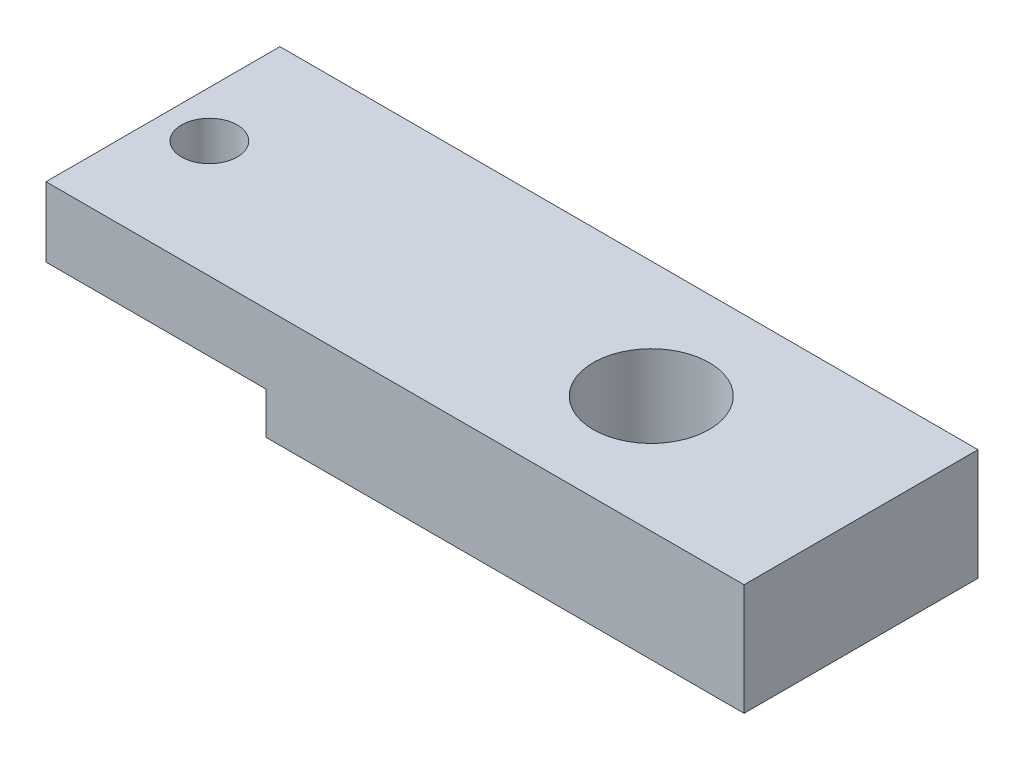
from build123d import *

# Parameters (mm, degrees)
SKETCH1_W           = 19.1008
SKETCH1_H           = 6.4008
BOSS_EXTRUDE1_DEPTH = 1.905
SKETCH2_W           = 13.081
SKETCH2_H           = 6.4008
BOSS_EXTRUDE2_DEPTH = 1.143
CUT_EXTRUDE1_REACH  = 5.048
SKETCH3_R           = 0.762
CUT_EXTRUDE2_REACH  = 5.048
SKETCH4_R           = 1.5875


with BuildPart() as part:
    # Sketch1 → Boss-Extrude1 (new body)
    with BuildSketch(Plane(origin=(0, 0, 0), x_dir=(1, 0, 0), z_dir=(0, 1, 0))):
        Rectangle(SKETCH1_W, SKETCH1_H)
    extrude(amount=BOSS_EXTRUDE1_DEPTH)

    # Sketch2 → Boss-Extrude2 (add)
    with BuildSketch(Plane(origin=(0, 0, 0), x_dir=(-1, 0, 0), z_dir=(0, -1, 0))):
        with Locations((-3.0099, 0)):
            Rectangle(SKETCH2_W, SKETCH2_H)
    extrude(amount=BOSS_EXTRUDE2_DEPTH)

    # Sketch3 → Cut-Extrude1 (cut, up to next)
    with BuildSketch(Plane(origin=(0, 1.905, 0), x_dir=(1, 0, 0), z_dir=(0, 1, 0)), mode=Mode.PRIVATE) as cut_extrude1_sk1:
        with Locations((-8.2804, 0)):
            Circle(SKETCH3_R)
    cut_extrude1_tool1 = extrude(cut_extrude1_sk1.sketch, amount=-CUT_EXTRUDE1_REACH, mode=Mode.PRIVATE) & part.part
    add(cut_extrude1_tool1.solids().sort_by_distance((-8.2804, 1.905, 0))[0], mode=Mode.SUBTRACT)

    # Sketch4 → Cut-Extrude2 (cut, up to next)
    with BuildSketch(Plane(origin=(0, 1.905, 0), x_dir=(1, 0, 0), z_dir=(0, 1, 0)), mode=Mode.PRIVATE) as cut_extrude2_sk1:
        with Locations((3.81, 0)):
            Circle(SKETCH4_R)
    cut_extrude2_tool1 = extrude(cut_extrude2_sk1.sketch, amount=-CUT_EXTRUDE2_REACH, mode=Mode.PRIVATE) & part.part
    add(cut_extrude2_tool1.solids().sort_by_distance((3.81, 1.905, 0))[0], mode=Mode.SUBTRACT)


solid = part.part
